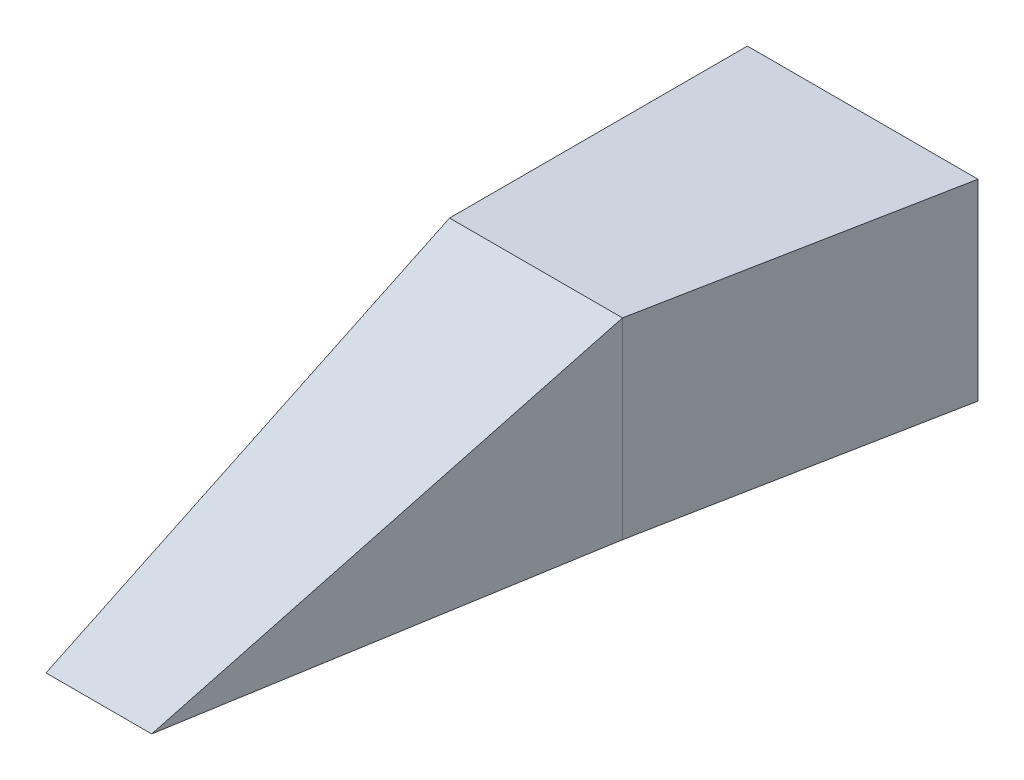
from build123d import *

# Parameters (mm, degrees)
BOSS_EXTRUDE1_DEPTH = 508
CUT_EXTRUDE1_DEPTH  = 508
BOSS_EXTRUDE2_DEPTH = 508


with BuildPart() as part:
    # Sketch1 → Boss-Extrude1 (new body)
    with BuildSketch(Plane(origin=(0, 0, 0), x_dir=(1, 0, 0), z_dir=(0, 1, 0))):
        Polygon((0, 1066.8), (0, 0), (279.4, 0), (457.2, 1066.8), align=None)
    extrude(amount=BOSS_EXTRUDE1_DEPTH)

    # Sketch2 → Cut-Extrude1 (cut)
    with BuildSketch(Plane.ZY):
        Polygon((0, 0), (-1066.8, 508), (-1066.8, 732.672417782), (0, 732.672417782), align=None)
    extrude(amount=-CUT_EXTRUDE1_DEPTH, mode=Mode.SUBTRACT)

    # Sketch3 → Boss-Extrude2 (add)
    with BuildSketch(Plane.XZ):
        Polygon((0, -1066.8), (0, -1854.2), (609.6, -1854.2), (457.2, -1066.8), align=None)
    extrude(amount=-BOSS_EXTRUDE2_DEPTH)


solid = part.part
